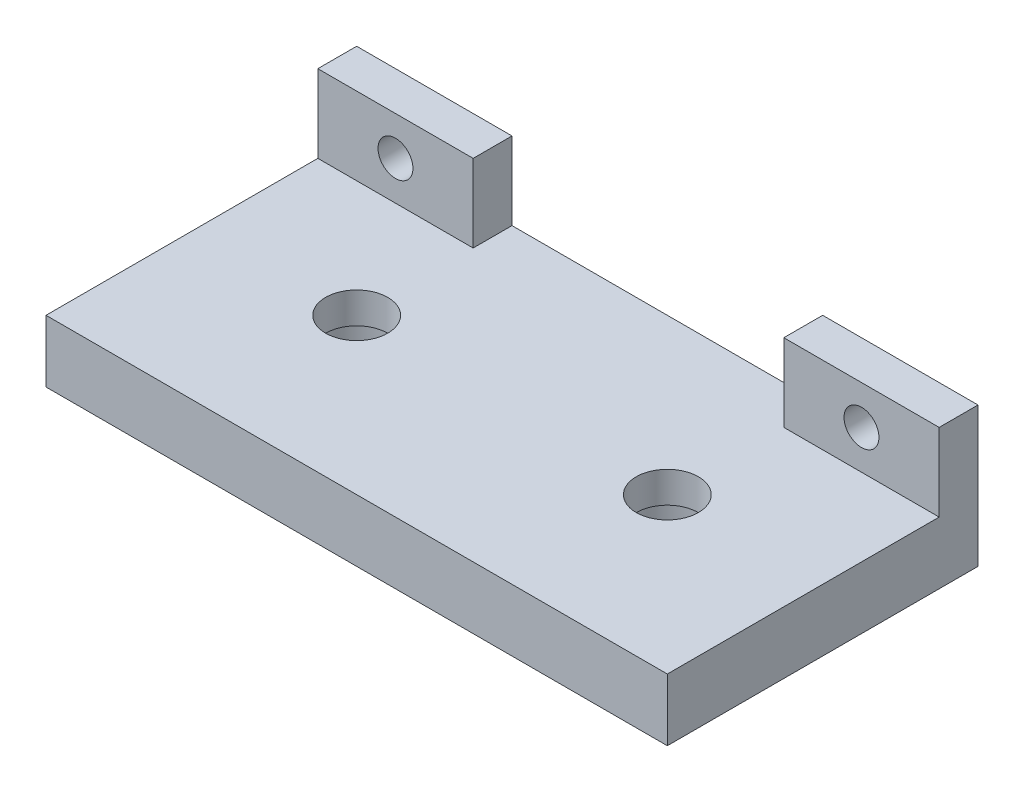
from build123d import *

# Parameters (mm, degrees)
SKETCH1_W                 = 80
SKETCH1_H                 = 40
BOSS_EXTRUDE1_DEPTH       = 8
SKETCH2_R                 = 4
CUT_EXTRUDE1_DEPTH        = 4
SKETCH3_W                 = 20
SKETCH3_H                 = 5
BOSS_EXTRUDE2_DEPTH       = 10
SKETCH5_R                 = 5.75
CUT_EXTRUDE3_DEPTH        = 4
F_8_CLEARANCE_HOLE1_D     = 4.4958
F_8_CLEARANCE_HOLE1_DEPTH = 5
F_8_CLEARANCE_HOLE1_TIP   = 1.350674586


with BuildPart() as part:
    # Sketch1 → Boss-Extrude1 (new body)
    with BuildSketch(Plane(origin=(0, 0, 0), x_dir=(1, 0, 0), z_dir=(0, 1, 0))):
        with Locations((-0.202602356, -13.338458494)):
            Rectangle(SKETCH1_W, SKETCH1_H)
    extrude(amount=BOSS_EXTRUDE1_DEPTH)

    # Sketch2 → Cut-Extrude1 (cut)
    with BuildSketch(Plane(origin=(0, 8, 0), x_dir=(1, 0, 0), z_dir=(0, 1, 0))):
        with Locations((19.797397644, -13.338458494)):
            Circle(SKETCH2_R)
        with Locations((-20.202602356, -13.338458494)):
            Circle(SKETCH2_R)
    extrude(amount=-CUT_EXTRUDE1_DEPTH, mode=Mode.SUBTRACT)

    # Sketch3 → Boss-Extrude2 (add)
    with BuildSketch(Plane(origin=(0, 8, 0), x_dir=(1, 0, 0), z_dir=(0, 1, 0))):
        with Locations((29.797397644, 4.161541506)):
            Rectangle(SKETCH3_W, SKETCH3_H)
        with Locations((-30.202602356, 4.161541506)):
            Rectangle(SKETCH3_W, SKETCH3_H)
    extrude(amount=BOSS_EXTRUDE2_DEPTH)

    # Sketch5 → Cut-Extrude3 (cut)
    with BuildSketch(Plane(origin=(0, 0, 0), x_dir=(-1, 0, 0), z_dir=(0, -1, 0))):
        with Locations((20.202602356, -13.338458494)):
            Circle(SKETCH5_R)
        with Locations((-19.797397644, -13.338458494)):
            Circle(SKETCH5_R)
    extrude(amount=-CUT_EXTRUDE3_DEPTH, mode=Mode.SUBTRACT)

    # #8 Clearance Hole1
    with Locations(Plane(origin=(29.797397644, 13, -6.661541506), x_dir=(-1, 0, 0), z_dir=(0, 0, -1))):
        with Locations((0, 0), (60, 0)):
            Hole(F_8_CLEARANCE_HOLE1_D / 2, depth=F_8_CLEARANCE_HOLE1_DEPTH)
            with Locations((0, 0, -(F_8_CLEARANCE_HOLE1_DEPTH + F_8_CLEARANCE_HOLE1_TIP / 2))):  # 118° drill point
                Cone(0, F_8_CLEARANCE_HOLE1_D / 2, F_8_CLEARANCE_HOLE1_TIP, mode=Mode.SUBTRACT)


solid = part.part
